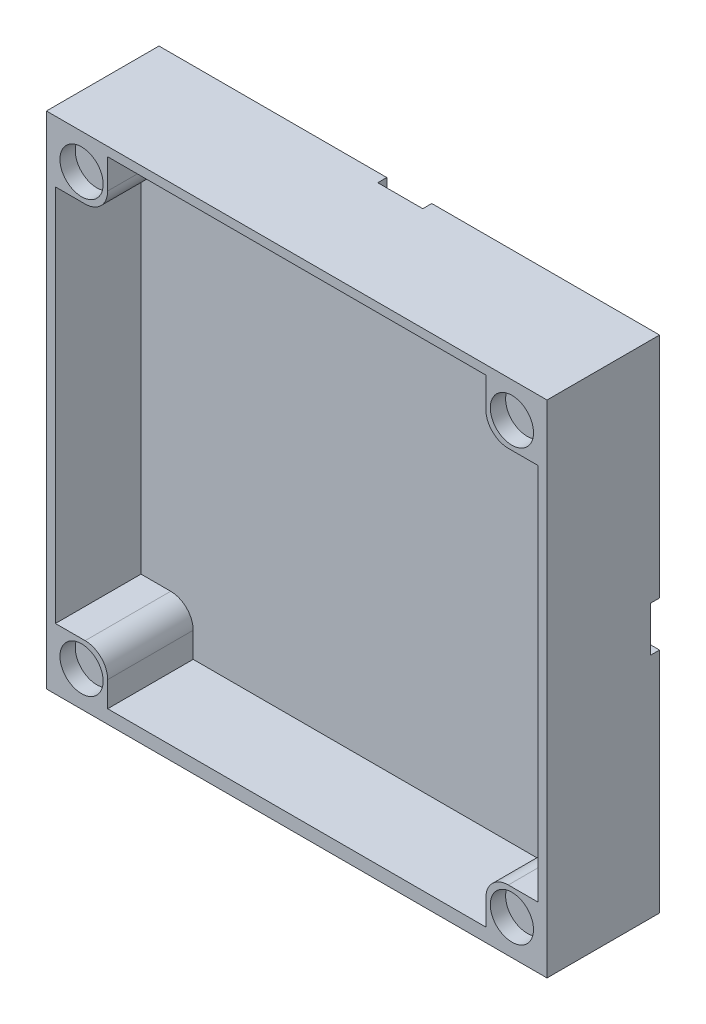
from build123d import *

# Parameters (mm, degrees)
SKICA1_W                 = 55.6
SKICA1_H                 = 55.6
P_IDAT_VYSUNUT_M2_DEPTH  = 3
SKICA5_W                 = 5
SKICA5_H                 = 25.3
ODEBRAT_VYSUNUT_M3_DEPTH = 1
SKICA14_W                = 53.6
SKICA14_H                = 1.5
P_IDAT_VYSUNUT_M9_DEPTH  = 9.5
SKICA17_R                = 2
ODEBRAT_VYSUNUT_M8_DEPTH = 4
SKICA19_W                = 6.8
SKICA19_H                = 6.8
P_IDAT_VYSUNUT_M10_DEPTH = 12.5
SKICA20_R                = 2.4
ODEBRAT_VYSUNUT_M9_DEPTH = 1.7
ZAOBLIT1_R               = 2.5
ZAOBLIT2_R               = 15
ZAOBLIT3_R               = 20


with BuildPart() as part:
    # Skica1 → Přidat vysunutím2 (new body)
    with BuildSketch(Plane.XY):
        Rectangle(SKICA1_W, SKICA1_H)
    extrude(amount=P_IDAT_VYSUNUT_M2_DEPTH)

    # Skica5 → Odebrat vysunutím3 (cut)
    with BuildSketch(Plane(origin=(0, 0, 0), x_dir=(-1, 0, 0), z_dir=(0, 0, -1))):
        Polygon((-2.5, 2.5), (-27.8, 2.5), (-27.8, -2.5), (2.5, -2.5), (2.5, 2.5), align=None)
        with Locations((0, 15.15)):
            Rectangle(SKICA5_W, SKICA5_H)
    extrude(amount=-ODEBRAT_VYSUNUT_M3_DEPTH, mode=Mode.SUBTRACT)

    # Skica14 → Přidat vysunutím9 (add)
    with BuildSketch(Plane.XY.offset(3)):
        Polygon((27.8, 27.8), (-27.8, 27.8), (-27.8, -27.8), (-26.8, -27.8), (-26.8, -26.8), (-26.8, -26.3), (-26.8, 26.8), (26.8, 26.8), (26.8, -26.3), (26.8, -27.8), (27.8, -27.8), align=None)
        with Locations((0, -27.05)):
            Rectangle(SKICA14_W, SKICA14_H)
    extrude(amount=P_IDAT_VYSUNUT_M9_DEPTH)

    # Skica17 → Odebrat vysunutím8 (cut)
    with BuildSketch(Plane(origin=(0, 0, 1), x_dir=(-1, 0, 0), z_dir=(0, 0, -1))):
        with Locations((-20.8, 0)):
            Circle(SKICA17_R)
        with Locations((0, 20.8)):
            Circle(SKICA17_R)
    extrude(amount=-ODEBRAT_VYSUNUT_M8_DEPTH, mode=Mode.SUBTRACT)

    # Skica19 → Přidat vysunutím10 (add)
    with BuildSketch(Plane(origin=(0, 0, 0), x_dir=(-1, 0, 0), z_dir=(0, 0, -1))):
        with Locations((-24.4, 24.4)):
            Rectangle(SKICA19_W, SKICA19_H)
        with Locations((24.4, 24.4)):
            Rectangle(SKICA19_W, SKICA19_H)
        with Locations((-24.4, -24.4)):
            Rectangle(SKICA19_W, SKICA19_H)
        with Locations((24.4, -24.4)):
            Rectangle(SKICA19_W, SKICA19_H)
    extrude(amount=-P_IDAT_VYSUNUT_M10_DEPTH)

    # Skica20 → Odebrat vysunutím9 (cut)
    with BuildSketch(Plane.XY.offset(12.5)):
        with Locations((-23.9, -23.9)):
            Circle(SKICA20_R)
        with Locations((-23.9, 23.9)):
            Circle(SKICA20_R)
        with Locations((23.900280565, 23.9)):
            Circle(SKICA20_R)
        with Locations((23.900280565, -23.9)):
            Circle(SKICA20_R)
    extrude(amount=-ODEBRAT_VYSUNUT_M9_DEPTH, mode=Mode.SUBTRACT)

    # Zaoblit1
    zaoblit1_edges = [part.edges().sort_by_distance(p)[0] for p in [
        (-21, 21, 7.75),
        (21, -21, 7.75),
        (-21, -21, 7.75),
        (21, 21, 7.75),
    ]]
    fillet(zaoblit1_edges, radius=ZAOBLIT1_R)

    # Zaoblit2
    zaoblit2_edges = [part.edges().sort_by_distance(p)[0] for p in [
        (2.5, 2.5, 0.5),
    ]]
    fillet(zaoblit2_edges, radius=ZAOBLIT2_R)

    # Zaoblit3
    zaoblit3_edges = [part.edges().sort_by_distance(p)[0] for p in [
        (-2.5, -2.5, 0.5),
    ]]
    fillet(zaoblit3_edges, radius=ZAOBLIT3_R)


solid = part.part
